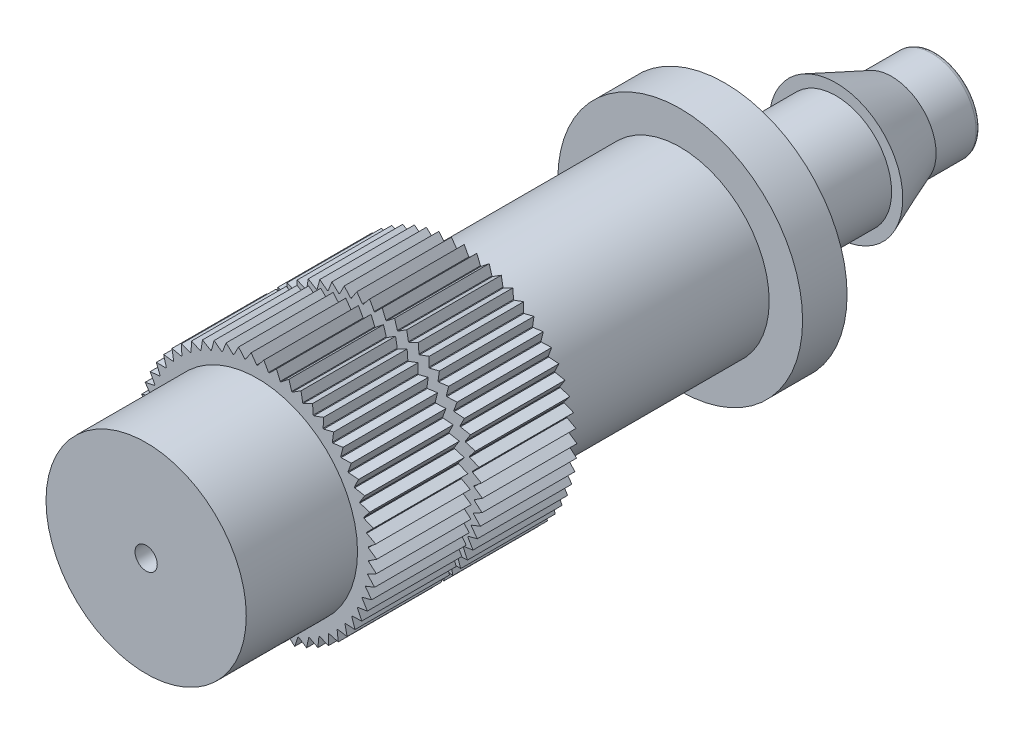
from build123d import *

# Parameters (mm, degrees)
SKETCH1_R           = 2
BOSS_EXTRUDE1_DEPTH = 2
SKETCH4_R           = 2.5
BOSS_EXTRUDE2_DEPTH = 5
SKETCH5_R           = 5.5
BOSS_EXTRUDE3_DEPTH = 2
SKETCH6_R           = 4
BOSS_EXTRUDE4_DEPTH = 10
FILLET2_R           = 0.2
BOSS_EXTRUDE5_DEPTH = 9
SKETCH8_R           = 5.466881928
SKETCH8_R_2         = 4
CUT_EXTRUDE1_DEPTH  = 0.25
SKETCH9_R           = 4.5
BOSS_EXTRUDE6_DEPTH = 5
SKETCH10_R          = 1.75
CUT_EXTRUDE2_DEPTH  = 33.5
SKETCH11_R          = 0.5
CUT_EXTRUDE3_DEPTH  = 1


with BuildPart() as part:
    # Sketch1 → Boss-Extrude1 (new body)
    with BuildSketch(Plane.XY):
        Circle(SKETCH1_R)
    extrude(amount=BOSS_EXTRUDE1_DEPTH)

    # Sketch3 → Revolve1 (revolve)
    with BuildSketch(Plane(origin=(0, 0, 0), x_dir=(1, 0, 0), z_dir=(0, 1, 0))):
        Polygon((0, -4.5), (0, -2), (-2, -2), (-3, -4.5), align=None)
    revolve(axis=Axis((0, 0, 4.5), (0, 0, -1)))

    # Sketch4 → Boss-Extrude2 (add)
    with BuildSketch(Plane.XY.offset(4.5)):
        Circle(SKETCH4_R)
    extrude(amount=BOSS_EXTRUDE2_DEPTH)

    # Sketch5 → Boss-Extrude3 (add)
    with BuildSketch(Plane.XY.offset(9.5)):
        Circle(SKETCH5_R)
    extrude(amount=BOSS_EXTRUDE3_DEPTH)

    # Sketch6 → Boss-Extrude4 (add)
    with BuildSketch(Plane.XY.offset(11.5)):
        Circle(SKETCH6_R)
    extrude(amount=BOSS_EXTRUDE4_DEPTH)

    # Fillet2
    fillet2_edges = [part.edges().sort_by_distance(p)[0] for p in [
        (-2, 0, 0),
    ]]
    fillet(fillet2_edges, radius=FILLET2_R)

    # Sketch7 → Boss-Extrude5 (add)
    with BuildSketch(Plane.XY.offset(21.5)):
        with BuildLine():
            Line((0.291028094, 5.354710344), (0, 5))
            ThreePointArc((0, 5), (-0.016132354, 4.999973975), (-0.032264539, 4.999895899))
            Line((-0.032264539, 4.999895899), (-0.279791465, 5.35530923))
            Line((-0.279791465, 5.35530923), (-0.531467428, 4.971674001))
            ThreePointArc((-0.531467428, 4.971674001), (-0.547505622, 4.969933359), (-0.563538117, 4.968140979))
            Line((-0.563538117, 4.968140979), (-0.847440875, 5.295230323))
            Line((-0.847440875, 5.295230323), (-1.056913118, 4.887016949))
            ThreePointArc((-1.056913118, 4.887016949), (-1.072675434, 4.883581413), (-1.088426583, 4.880095037))
            Line((-1.088426583, 4.880095037), (-1.405488442, 5.175154341))
            Line((-1.405488442, 5.175154341), (-1.57038356, 4.746988042))
            ThreePointArc((-1.57038356, 4.746988042), (-1.585691404, 4.741896537), (-1.600982741, 4.736755669))
            Line((-1.600982741, 4.736755669), (-1.947611263, 4.996441792))
            Line((-1.947611263, 4.996441792), (-2.066060929, 4.553173864))
            ThreePointArc((-2.066060929, 4.553173864), (-2.080740857, 4.54648408), (-2.095399124, 4.539746965))
            Line((-2.095399124, 4.539746965), (-2.46766687, 4.761117562))
            Line((-2.46766687, 4.761117562), (-2.538329002, 4.307770407))
            ThreePointArc((-2.538329002, 4.307770407), (-2.552214685, 4.299558141), (-2.566073798, 4.291301115))
            Line((-2.566073798, 4.291301115), (-2.959762825, 4.471847966))
            Line((-2.959762825, 4.471847966), (-2.981836793, 4.01355819))
            ThreePointArc((-2.981836793, 4.01355819), (-2.9947709, 4.00391649), (-3.007673831, 3.994233108))
            Line((-3.007673831, 3.994233108), (-3.418323485, 4.131910547))
            Line((-3.418323485, 4.131910547), (-3.391559181, 3.673870754))
            ThreePointArc((-3.391559181, 3.673870754), (-3.403395164, 3.662908865), (-3.415195718, 3.651908845))
            Line((-3.415195718, 3.651908845), (-3.838153174, 3.74515693))
            Line((-3.838153174, 3.74515693), (-3.762853849, 3.292556895))
            ThreePointArc((-3.762853849, 3.292556895), (-3.773457602, 3.28039902), (-3.784022072, 3.268206994))
            Line((-3.784022072, 3.268206994), (-4.214495054, 3.315969188))
            Line((-4.214495054, 3.315969188), (-4.09151388, 2.873937051))
            ThreePointArc((-4.09151388, 2.873937051), (-4.100765257, 2.860720942), (-4.109973944, 2.847475053))
            Line((-4.109973944, 2.847475053), (-4.54308502, 2.849210191))
            Line((-4.54308502, 2.849210191), (-4.373815423, 2.422754352))
            ThreePointArc((-4.373815423, 2.422754352), (-4.381609603, 2.408629754), (-4.389358169, 2.394480082))
            Line((-4.389358169, 2.394480082), (-4.820200019, 2.350168503))
            Line((-4.820200019, 2.350168503), (-4.606559889, 1.944120877))
            ThreePointArc((-4.606559889, 1.944120877), (-4.612808561, 1.929247828), (-4.619009213, 1.914354694))
            Line((-4.619009213, 1.914354694), (-5.042700225, 1.824498468))
            Line((-5.042700225, 1.824498468), (-4.787110192, 1.443459737))
            ThreePointArc((-4.787110192, 1.443459737), (-4.791742555, 1.428006753), (-4.796325036, 1.412538903))
            Line((-4.796325036, 1.412538903), (-5.208064622, 1.278156135))
            Line((-5.208064622, 1.278156135), (-4.913420623, 0.92644362))
            ThreePointArc((-4.913420623, 0.92644362), (-4.916384191, 0.910585791), (-4.91929658, 0.894718481))
            Line((-4.91929658, 0.894718481), (-5.314419566, 0.717331783))
            Line((-5.314419566, 0.717331783), (-4.984060035, 0.398930528))
            ThreePointArc((-4.984060035, 0.398930528), (-4.98532123, 0.382847528), (-4.986530528, 0.366760542))
            Line((-4.986530528, 0.366760542), (-5.360560013, 0.148379776))
            Line((-5.360560013, 0.148379776), (-4.998228056, -0.133102607))
            ThreePointArc((-4.998228056, -0.133102607), (-4.997772588, -0.149228551), (-4.997265093, -0.165352941))
            Line((-4.997265093, -0.165352941), (-5.345963173, -0.422253434))
            Line((-5.345963173, -0.422253434), (-4.955764155, -0.663627636))
            ThreePointArc((-4.955764155, -0.663627636), (-4.953597185, -0.67961381), (-4.951378647, -0.695592909))
            Line((-4.951378647, -0.695592909), (-5.270794435, -0.988102344))
            Line((-5.270794435, -0.988102344), (-4.857149466, -1.186633499))
            ThreePointArc((-4.857149466, -1.186633499), (-4.853295546, -1.202298773), (-4.849391103, -1.217951531))
            Line((-4.849391103, -1.217951531), (-5.135905489, -1.542755659))
            Line((-5.135905489, -1.542755659), (-4.703501333, -1.696194331))
            ThreePointArc((-4.703501333, -1.696194331), (-4.69800413, -1.711361211), (-4.69245802, -1.726510276))
            Line((-4.69245802, -1.726510276), (-4.942824682, -2.079928937))
            Line((-4.942824682, -2.079928937), (-4.496560651, -2.186536602))
            ThreePointArc((-4.496560651, -2.186536602), (-4.48948245, -2.201033242), (-4.482357512, -2.21550697))
            Line((-4.482357512, -2.21550697), (-4.693739696, -2.593535788))
            Line((-4.693739696, -2.593535788), (-4.238672139, -2.652104541))
            ThreePointArc((-4.238672139, -2.652104541), (-4.230093139, -2.665766688), (-4.221470103, -2.679401084))
            Line((-4.221470103, -2.679401084), (-4.391472763, -3.077756843))
            Line((-4.391472763, -3.077756843), (-3.932757779, -3.087623075))
            ThreePointArc((-3.932757779, -3.087623075), (-3.922775183, -3.100295931), (-3.912751751, -3.112936513))
            Line((-3.912751751, -3.112936513), (-4.03944869, -3.527105682))
            Line((-4.03944869, -3.527105682), (-3.582283701, -3.488157606))
            ThreePointArc((-3.582283701, -3.488157606), (-3.571010617, -3.499697583), (-3.559700358, -3.511201128))
            Line((-3.559700358, -3.511201128), (-3.641656049, -3.936491005))
            Line((-3.641656049, -3.936491005), (-3.191220918, -3.849169917))
            ThreePointArc((-3.191220918, -3.849169917), (-3.178785074, -3.859446263), (-3.166316138, -3.869682431))
            Line((-3.166316138, -3.869682431), (-3.20260199, -4.301274312))
            Line((-3.20260199, -4.301274312), (-2.764000327, -4.166569595))
            ThreePointArc((-2.764000327, -4.166569595), (-2.750542625, -4.175465874), (-2.73705629, -4.184318686))
            Line((-2.73705629, -4.184318686), (-2.72726117, -4.617322463))
            Line((-2.72726117, -4.617322463), (-2.305462507, -4.436760375))
            ThreePointArc((-2.305462507, -4.436760375), (-2.29113543, -4.444175789), (-2.276784501, -4.451544938))
            Line((-2.276784501, -4.451544938), (-2.221019392, -4.881054504))
            Line((-2.221019392, -4.881054504), (-1.820802876, -4.656680887))
            ThreePointArc((-1.820802876, -4.656680887), (-1.805768754, -4.662531416), (-1.790715834, -4.668333407))
            Line((-1.790715834, -4.668333407), (-1.689612576, -5.089482248))
            Line((-1.689612576, -5.089482248), (-1.315512821, -4.823839344))
            ThreePointArc((-1.315512821, -4.823839344), (-1.299941997, -4.828058699), (-1.284357641, -4.832227794))
            Line((-1.284357641, -4.832227794), (-1.139061775, -5.240244125))
            Line((-1.139061775, -5.240244125), (-0.79531748, -4.936341774))
            ThreePointArc((-0.79531748, -4.936341774), (-0.779386378, -4.938882148), (-0.763447163, -4.941371108))
            Line((-0.763447163, -4.941371108), (-0.575604949, -5.331631941))
            Line((-0.575604949, -5.331631941), (-0.266110874, -4.992913478))
            ThreePointArc((-0.266110874, -4.992913478), (-0.25, -4.993746089), (-0.233886523, -4.994526714))
            Line((-0.233886523, -4.994526714), (-0.005626289, -5.362610238))
            Line((-0.005626289, -5.362610238), (0.266110874, -4.992913478))
            ThreePointArc((0.266110874, -4.992913478), (0.282218978, -4.992028891), (0.298324144, -4.991092336))
            Line((0.298324144, -4.991092336), (0.56441612, -5.332828017))
            Line((0.56441612, -5.332828017), (0.79531748, -4.936341774))
            ThreePointArc((0.79531748, -4.936341774), (0.811240303, -4.933750011), (0.82715468, -4.931106887))
            Line((0.82715468, -4.931106887), (1.128063468, -5.242622724))
            Line((1.128063468, -5.242622724), (1.315512821, -4.823839344))
            ThreePointArc((1.315512821, -4.823839344), (1.33106995, -4.819569772), (1.346613223, -4.815250028))
            Line((1.346613223, -4.815250028), (1.678929406, -5.093016421))
            Line((1.678929406, -5.093016421), (1.820802876, -4.656680887))
            ThreePointArc((1.820802876, -4.656680887), (1.835818043, -4.650781882), (1.850814099, -4.644834461))
            Line((1.850814099, -4.644834461), (2.210772403, -4.885704207))
            Line((2.210772403, -4.885704207), (2.305462507, -4.436760375))
            ThreePointArc((2.305462507, -4.436760375), (2.319765585, -4.429298774), (2.334044513, -4.421791064))
            Line((2.334044513, -4.421791064), (2.717566466, -4.623035011))
            Line((2.717566466, -4.623035011), (2.764000327, -4.166569595))
            ThreePointArc((2.764000327, -4.166569595), (2.777429255, -4.157629942), (2.790829269, -4.148647007))
            Line((2.790829269, -4.148647007), (3.193569415, -4.307984982))
            Line((3.193569415, -4.307984982), (3.191220918, -3.849169917))
            ThreePointArc((3.191220918, -3.849169917), (3.203623542, -3.838853501), (3.215992815, -3.828497122))
            Line((3.215992815, -3.828497122), (3.633387946, -3.944123762))
            Line((3.633387946, -3.944123762), (3.582283701, -3.488157606))
            ThreePointArc((3.582283701, -3.488157606), (3.593519494, -3.476581316), (3.604717877, -3.464968835))
            Line((3.604717877, -3.464968835), (4.03203874, -3.535574043))
            Line((4.03203874, -3.535574043), (3.932757779, -3.087623075))
            ThreePointArc((3.932757779, -3.087623075), (3.942699434, -3.074918076), (3.952600045, -3.062181066))
            Line((3.952600045, -3.062181066), (4.385004924, -3.086964858))
            Line((4.385004924, -3.086964858), (4.238672139, -2.652104541))
            ThreePointArc((4.238672139, -2.652104541), (4.247207014, -2.638414785), (4.255697675, -2.624697563))
            Line((4.255697675, -2.624697563), (4.688287249, -2.603379128))
            Line((4.688287249, -2.603379128), (4.496560651, -2.186536602))
            ThreePointArc((4.496560651, -2.186536602), (4.503592042, -2.1720172), (4.510576551, -2.157475187))
            Line((4.510576551, -2.157475187), (4.938449407, -2.090296071))
            Line((4.938449407, -2.090296071), (4.703501333, -1.696194331))
            ThreePointArc((4.703501333, -1.696194331), (4.708949573, -1.681009792), (4.714348791, -1.665807755))
            Line((4.714348791, -1.665807755), (5.13265696, -1.553529125))
            Line((5.13265696, -1.553529125), (4.857149466, -1.186633499))
            ThreePointArc((4.857149466, -1.186633499), (4.860952823, -1.170955872), (4.864705576, -1.155266056))
            Line((4.864705576, -1.155266056), (5.268709459, -0.999160073))
            Line((5.268709459, -0.999160073), (4.955764155, -0.663627636))
            ThreePointArc((4.955764155, -0.663627636), (4.957879535, -0.647634554), (4.959943303, -0.63163473))
            Line((4.959943303, -0.63163473), (5.345065374, -0.433470139))
            Line((5.345065374, -0.433470139), (4.998228056, -0.133102607))
            ThreePointArc((4.998228056, -0.133102607), (4.998631491, -0.116975278), (4.99898289, -0.100846731))
            Line((4.99898289, -0.100846731), (5.360859563, 0.137131186))
            Line((5.360859563, 0.137131186), (4.984060035, 0.398930528))
            ThreePointArc((4.984060035, 0.398930528), (4.982746955, 0.415009375), (4.981382004, 0.431083902))
            Line((4.981382004, 0.431083902), (5.315913071, 0.706178759))
            Line((5.315913071, 0.706178759), (4.913420623, 0.92644362))
            ThreePointArc((4.913420623, 0.92644362), (4.910405905, 0.942291806), (4.907340069, 0.958130182))
            Line((4.907340069, 0.958130182), (5.210735159, 1.267225045))
            Line((5.210735159, 1.267225045), (4.787110192, 1.443459737))
            ThreePointArc((4.787110192, 1.443459737), (4.782427994, 1.458897694), (4.77769601, 1.474320464))
            Line((4.77769601, 1.474320464), (5.046517536, 1.813913165))
            Line((5.046517536, 1.813913165), (4.606559889, 1.944120877))
            ThreePointArc((4.606559889, 1.944120877), (4.600263263, 1.958973689), (4.593918747, 1.973806107))
            Line((4.593918747, 1.973806107), (4.825120853, 2.340048924))
            Line((4.825120853, 2.340048924), (4.373815423, 2.422754352))
            ThreePointArc((4.373815423, 2.422754352), (4.365975711, 2.436853728), (4.358090548, 2.450927737))
            Line((4.358090548, 2.450927737), (4.549053623, 2.839670993))
            Line((4.549053623, 2.839670993), (4.09151388, 2.873937051))
            ThreePointArc((4.09151388, 2.873937051), (4.082219909, 2.887123242), (4.072883442, 2.900279377))
            Line((4.072883442, 2.900279377), (4.221443797, 3.307118456))
            Line((4.221443797, 3.307118456), (3.762853849, 3.292556895))
            ThreePointArc((3.762853849, 3.292556895), (3.752210925, 3.304680495), (3.74152894, 3.316769693))
            Line((3.74152894, 3.316769693), (3.846003327, 3.737094945))
            Line((3.846003327, 3.737094945), (3.391559181, 3.673870754))
            ThreePointArc((3.391559181, 3.673870754), (3.379687892, 3.684794398), (3.367781419, 3.695679682))
            Line((3.367781419, 3.695679682), (3.426986102, 4.124728655))
            Line((3.426986102, 4.124728655), (2.981836793, 4.01355819))
            ThreePointArc((2.981836793, 4.01355819), (2.968871644, 4.023158108), (2.955875589, 4.032716144))
            Line((2.955875589, 4.032716144), (2.969139755, 4.465627541))
            Line((2.969139755, 4.465627541), (2.538329002, 4.307770407))
            ThreePointArc((2.538329002, 4.307770407), (2.524416894, 4.315937829), (2.510478508, 4.324060321))
            Line((2.510478508, 4.324060321), (2.477651868, 4.755929082))
            Line((2.477651868, 4.755929082), (2.066060929, 4.553173864))
            ThreePointArc((2.066060929, 4.553173864), (2.051359493, 4.55981625), (2.036636702, 4.566411167))
            Line((2.036636702, 4.566411167), (1.958091195, 4.992344047))
            Line((1.958091195, 4.992344047), (1.57038356, 4.746988042))
            ThreePointArc((1.57038356, 4.746988042), (1.555059368, 4.75203013), (1.539718988, 4.757022749))
            Line((1.539718988, 4.757022749), (1.416344567, 5.172193759))
            Line((1.416344567, 5.172193759), (1.056913118, 4.887016949))
            ThreePointArc((1.056913118, 4.887016949), (1.0411398, 4.890401611), (1.025355643, 4.893735363))
            Line((1.025355643, 4.893735363), (0.858550189, 5.293440449))
            Line((0.858550189, 5.293440449), (0.531467428, 4.971674001))
            ThreePointArc((0.531467428, 4.971674001), (0.515423701, 4.973362887), (0.499374609, 4.975))
            Line((0.499374609, 4.975), (0.291028094, 5.354710344))
        make_face()
    extrude(amount=BOSS_EXTRUDE5_DEPTH)

    # Sketch8 → Cut-Extrude1 (cut, symmetric)
    with BuildSketch(Plane.XY.offset(26)):
        Circle(SKETCH8_R)
        Circle(SKETCH8_R_2, mode=Mode.SUBTRACT)
    extrude(amount=CUT_EXTRUDE1_DEPTH, both=True, mode=Mode.SUBTRACT)

    # Sketch9 → Boss-Extrude6 (add)
    with BuildSketch(Plane.XY.offset(30.5)):
        Circle(SKETCH9_R)
    extrude(amount=BOSS_EXTRUDE6_DEPTH)

    # Sketch10 → Cut-Extrude2 (cut)
    with BuildSketch(Plane(origin=(0, 0, 0), x_dir=(-1, 0, 0), z_dir=(0, 0, -1))):
        Circle(SKETCH10_R)
    extrude(amount=-CUT_EXTRUDE2_DEPTH, mode=Mode.SUBTRACT)

    # Sketch11 → Cut-Extrude3 (cut)
    with BuildSketch(Plane.XY.offset(35.5)):
        Circle(SKETCH11_R)
    extrude(amount=-CUT_EXTRUDE3_DEPTH, mode=Mode.SUBTRACT)


solid = part.part
